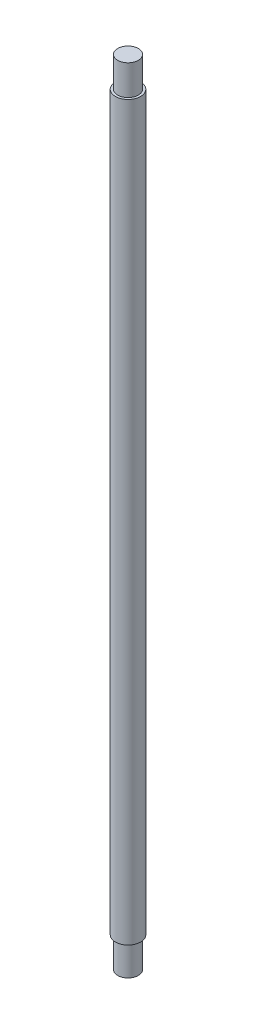
from build123d import *

# Parameters (mm, degrees)
SKETCH1_R           = 82.5
BOSS_EXTRUDE1_DEPTH = 5195
SKETCH2_R           = 82.5
SKETCH2_R_2         = 67.5
CUT_EXTRUDE1_DEPTH  = 197.5
SKETCH3_R           = 82.5
SKETCH3_R_2         = 67.5
CUT_EXTRUDE2_DEPTH  = 197.5


with BuildPart() as part:
    # Sketch1 → Boss-Extrude1 (new body)
    with BuildSketch(Plane(origin=(0, 0, 0), x_dir=(1, 0, 0), z_dir=(0, 1, 0))):
        Circle(SKETCH1_R)
    extrude(amount=BOSS_EXTRUDE1_DEPTH)

    # Sketch2 → Cut-Extrude1 (cut)
    with BuildSketch(Plane.XZ):
        Circle(SKETCH2_R)
        Circle(SKETCH2_R_2, mode=Mode.SUBTRACT)
    extrude(amount=-CUT_EXTRUDE1_DEPTH, mode=Mode.SUBTRACT)

    # Sketch3 → Cut-Extrude2 (cut)
    with BuildSketch(Plane(origin=(0, 5195, 0), x_dir=(1, 0, 0), z_dir=(0, 1, 0))):
        Circle(SKETCH3_R)
        Circle(SKETCH3_R_2, mode=Mode.SUBTRACT)
    extrude(amount=-CUT_EXTRUDE2_DEPTH, mode=Mode.SUBTRACT)


solid = part.part
